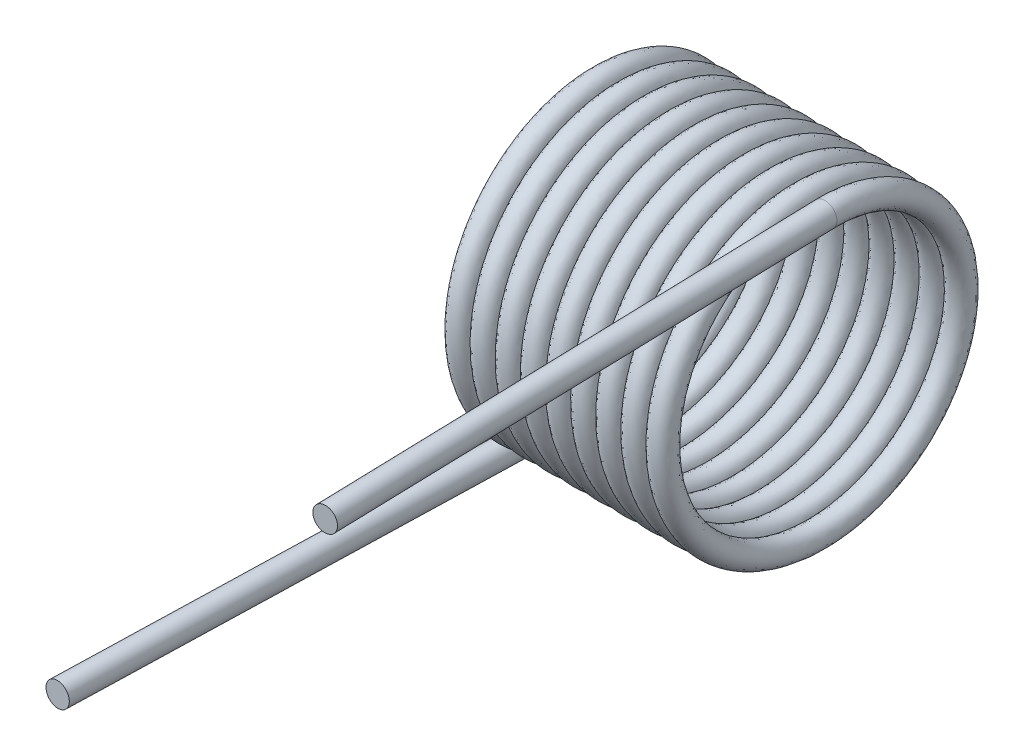
from build123d import *

# Parameters (mm, degrees)
SWEEP1_PITCH       = 0.5588
SWEEP1_HEIGHT      = 5.3086
SWEEP1_RADIUS      = 3.175
SWEEP1_START_ANGLE = 90
SKETCH2_R          = 0.2667
SKETCH3_R          = 0.2667
EXTRUDE1_DEPTH     = 11.43
SKETCH4_R          = 0.2667
EXTRUDE2_DEPTH     = 11.43


with BuildPart() as part:
    # Sweep1: sweep along a helix
    with BuildLine() as sweep1_path:
        add(Helix(SWEEP1_PITCH, SWEEP1_HEIGHT, SWEEP1_RADIUS, center=(0, 0, 0), direction=(1, 0, 0), mode=Mode.PRIVATE).rotate(Axis((0, 0, 0), (1, 0, 0)), SWEEP1_START_ANGLE))
    # Sketch2 → Sweep1 (sweep)
    with BuildSketch(Plane(origin=(0, -3.175, 0), x_dir=(0.998182347, 0.053387455, 0.027960355), z_dir=(0.028000287, 0, -0.999607915))):
        Circle(SKETCH2_R)
    sweep(path=sweep1_path.line, is_frenet=True)

    # Sketch3 → Extrude1 (add)
    with BuildSketch(Plane(origin=(0, 0, 0), x_dir=(-0.998182347, -0.053387455, -0.027960355), z_dir=(-0.028000287, 0, 0.999607915))):
        with Locations((0.169505171, 3.170472046)):
            Circle(SKETCH3_R)
    extrude(amount=EXTRUDE1_DEPTH)

    # Sketch4 → Extrude2 (add)
    with BuildSketch(Plane(origin=(0.004162028, 0, 0.148584044), x_dir=(0.999446018, 0.017997072, -0.027995752), z_dir=(0.028000287, 0, 0.999607915))):
        with Locations((5.362799835, 3.07898398)):
            Circle(SKETCH4_R)
    extrude(amount=EXTRUDE2_DEPTH)


solid = part.part
